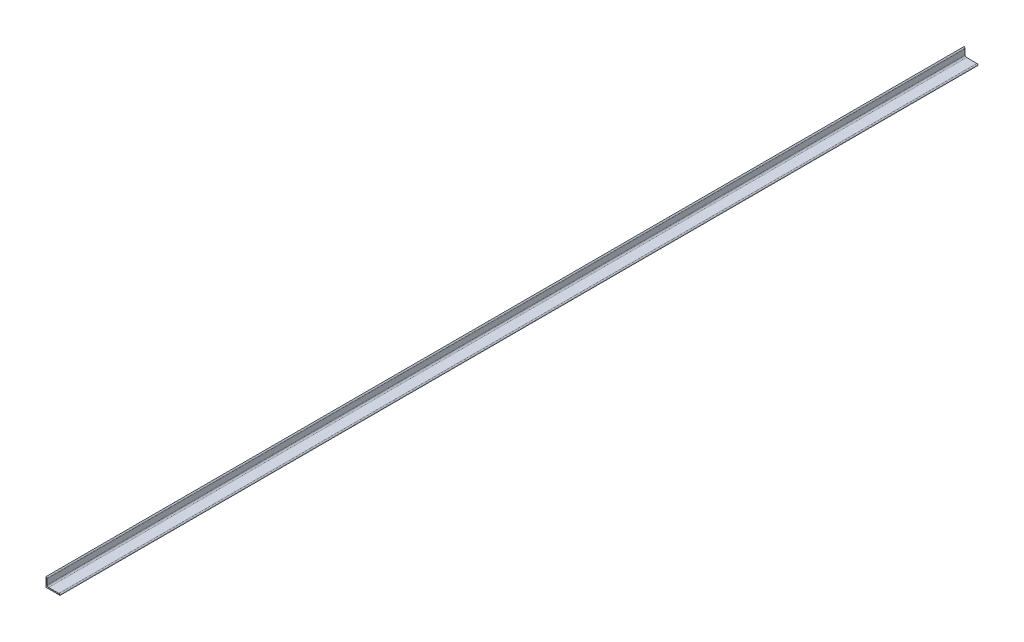
from build123d import *

# Parameters (mm, degrees)
COMPONENTE_ESTRUTURAL1_DEPTH = 5000


with BuildPart() as part:
    # Sketch11 → Componente estrutural1 (new body)
    with BuildSketch(Plane.YX):
        with BuildLine():
            Line((0, 0), (0, 76.2))
            Line((0, 76.2), (0.00508, 76.2))
            ThreePointArc((0.00508, 76.2), (4.491615958, 74.341615958), (6.35, 69.85508))
            Line((6.35, 69.85508), (6.35, 14.2875))
            ThreePointArc((6.35, 14.2875), (8.674839924, 8.674839924), (14.2875, 6.35))
            Line((14.2875, 6.35), (44.45508, 6.35))
            ThreePointArc((44.45508, 6.35), (48.941615958, 4.491615958), (50.8, 0.00508))
            Line((50.8, 0.00508), (50.8, 0))
            Line((50.8, 0), (0, 0))
        make_face()
    extrude(amount=COMPONENTE_ESTRUTURAL1_DEPTH)


solid = part.part
